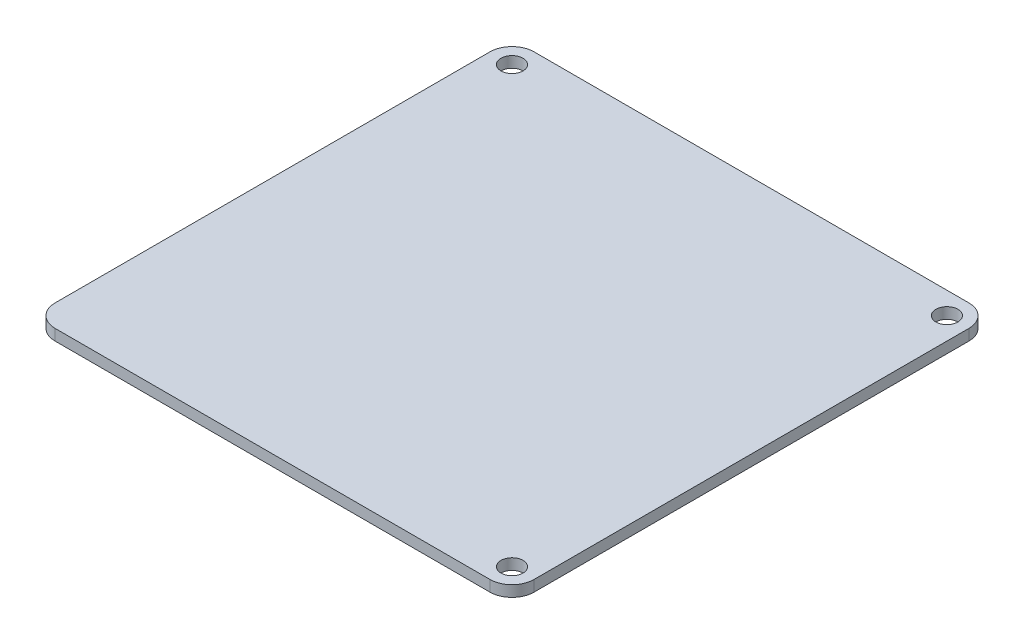
from build123d import *

# Parameters (mm, degrees)
SKETCH1_R           = 3.175
BOSS_EXTRUDE1_DEPTH = 3.175


with BuildPart() as part:
    # Sketch1 → Boss-Extrude1 (new body)
    with BuildSketch(Plane(origin=(0, 0, 0), x_dir=(1, 0, 0), z_dir=(0, 1, 0))):
        with BuildLine():
            Line((-0.993506611, -8.434604242), (124.267660571, -8.434604242))
            ThreePointArc((124.267660571, -8.434604242), (128.757788632, -6.574732303), (130.617660571, -2.084604242))
            Line((130.617660571, -2.084604242), (130.617660571, 123.176562941))
            ThreePointArc((130.617660571, 123.176562941), (128.757788632, 127.666691001), (124.267660571, 129.526562941))
            Line((124.267660571, 129.526562941), (-0.993506611, 129.526562941))
            ThreePointArc((-0.993506611, 129.526562941), (-5.483634672, 127.666691001), (-7.343506611, 123.176562941))
            Line((-7.343506611, 123.176562941), (-7.343506611, -2.084604242))
            ThreePointArc((-7.343506611, -2.084604242), (-5.483634672, -6.574732303), (-0.993506611, -8.434604242))
        make_face()
        with Locations(Location((124.267660571, -2.084604242, 0), (0, 0, 270))):
            Circle(SKETCH1_R, mode=Mode.SUBTRACT)
        with Locations(Location((124.267660571, 123.176562941, 0), (0, 0, 270))):
            Circle(SKETCH1_R, mode=Mode.SUBTRACT)
        with Locations(Location((-0.993506611, 123.176562941, 0), (0, 0, 270))):
            Circle(SKETCH1_R, mode=Mode.SUBTRACT)
        with BuildLine():
            Line((20.247476788, 4.265395758), (117.917660571, 4.265395758))
            Line((117.917660571, 4.265395758), (117.917660571, 116.826562941))
            Line((117.917660571, 116.826562941), (5.356493389, 116.826562941))
            Line((5.356493389, 116.826562941), (5.356493389, 50.943180056))
            ThreePointArc((5.356493389, 50.943180056), (3.835119849, 46.819241828), (0, 44.671382498))
            Line((0, 44.671382498), (0, 0))
            Line((0, 0), (14.2494, 0))
            ThreePointArc((14.2494, 0), (16.56744533, 3.090322663), (20.247476788, 4.265395758))
        make_face(mode=Mode.SUBTRACT)
        with BuildLine():
            ThreePointArc((20.247476788, 4.265395758), (16.56744533, 3.090322663), (14.2494, 0))
            Line((14.2494, 0), (0, 0))
            Line((0, 0), (0, 44.671382498))
            ThreePointArc((0, 44.671382498), (3.835119849, 46.819241828), (5.356493389, 50.943180056))
            Line((5.356493389, 50.943180056), (5.356493389, 116.826562941))
            Line((5.356493389, 116.826562941), (117.917660571, 116.826562941))
            Line((117.917660571, 116.826562941), (117.917660571, 4.265395758))
            Line((117.917660571, 4.265395758), (20.247476788, 4.265395758))
        make_face()
    extrude(amount=BOSS_EXTRUDE1_DEPTH)


solid = part.part
